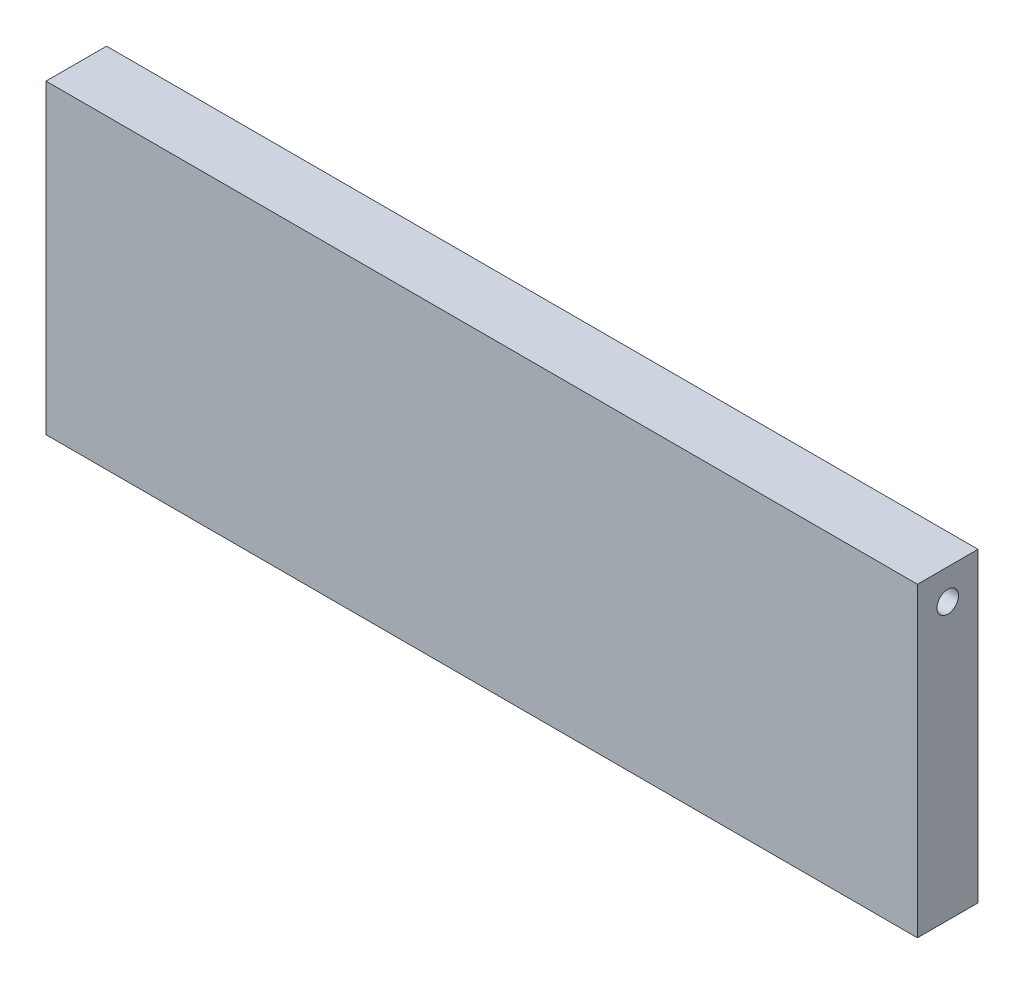
from build123d import *

# Parameters (mm, degrees)
SKETCH1_W           = 91.44
SKETCH1_H           = 6.35
BOSS_EXTRUDE1_DEPTH = 32.131
SKETCH2_R           = 1.1303
CUT_EXTRUDE1_DEPTH  = 12.7


with BuildPart() as part:
    # Sketch1 → Boss-Extrude1 (new body)
    with BuildSketch(Plane(origin=(0, 0, 0), x_dir=(1, 0, 0), z_dir=(0, 1, 0))):
        with Locations((-45.72, -3.175)):
            Rectangle(SKETCH1_W, SKETCH1_H)
    extrude(amount=BOSS_EXTRUDE1_DEPTH)

    # Sketch2 → Cut-Extrude1 (cut)
    with BuildSketch(Plane(origin=(0, 0, 0), x_dir=(0, 0, -1), z_dir=(1, 0, 0))):
        with Locations((-3.175, 28.956)):
            Circle(SKETCH2_R)
    cut_extrude1 = extrude(amount=-CUT_EXTRUDE1_DEPTH, mode=Mode.SUBTRACT)

    # Mirror1: Cut-Extrude1 across plane
    add(cut_extrude1.mirror(Plane(origin=(-45.72, 0, 0), x_dir=(0, 0, 1), z_dir=(1, 0, 0))), mode=Mode.SUBTRACT)


solid = part.part
